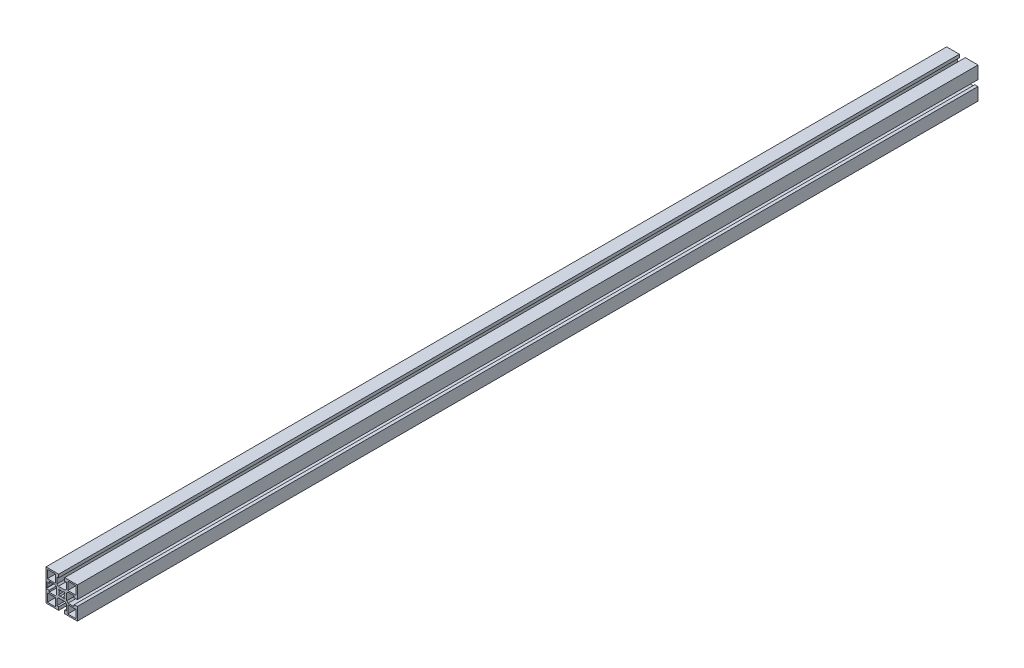
from build123d import *

# Parameters (mm, degrees)
SKETCH1_W           = 11.699975178
SKETCH1_H           = 11.699996949
SKETCH1_W_2         = 11.699990436
SKETCH1_H_2         = 11.699981689
SKETCH1_W_3         = 11.699990437
SKETCH1_H_3         = 11.699975177
SKETCH1_W_4         = 11.699981689
SKETCH1_H_4         = 11.699990436
BOSS_EXTRUDE1_DEPTH = 1292.86
CUT_EXTRUDE1_REACH  = 1295.252


with BuildPart() as part:
    # Sketch1 → Boss-Extrude1 (new body)
    with BuildSketch(Plane.XY):
        Polygon((22.500515052, 22.499297556), (-22.499484399, 22.499298105), (-22.499484948, -22.500701346), (-4.249491942, -22.500701568), (-4.249491942, -22.200733242), (-4.24949208, -18.000719999), (-6.799479919, -18.000719999), (-6.799480207, -9.200732353), (-4.799480391, -7.200732362), (4.800525817, -7.200732047), (6.8005258, -9.200731855), (6.800526088, -18.000720263), (4.250507877, -18.000720263), (4.250508015, -22.200733153), (4.250508015, -22.500701672), (22.500514502, -22.500701895), (22.500514725, -4.250714302), (22.200520351, -4.250714302), (18.000507108, -4.25071444), (18.000507108, -6.800702279), (9.200519462, -6.800702567), (7.200519471, -4.800702751), (7.200519156, 4.799303458), (9.200518964, 6.79930344), (18.000507424, 6.799303729), (18.000507424, 4.249285514), (22.200520261, 4.249285652), (22.500514829, 4.249285652), align=None)
        with BuildLine():
            Line((-4.249491247, 17.999291576), (-4.249490956, 22.199304807))
            Line((-4.249490956, 22.199304807), (-3.949472548, 22.199304807))
            Line((-3.949472548, 22.199304807), (-3.481695222, 21.73152644))
            ThreePointArc((-3.481695222, 21.73152644), (-2.670636178, 21.189593132), (-1.713926324, 20.999291428))
            Line((-1.713926324, 20.999291428), (1.714975167, 20.999291428))
            ThreePointArc((1.714975167, 20.999291428), (2.671722509, 21.189608628), (3.482801459, 21.731583767))
            Line((3.482801459, 21.731583767), (3.950490798, 22.199304487))
            Line((3.950490798, 22.199304487), (4.250509108, 22.199304487))
            Line((4.250509108, 22.199304487), (4.250508817, 17.999291575))
            Line((4.250508817, 17.999291575), (6.800527063, 17.999291575))
            Line((6.800527063, 17.999291575), (6.800526453, 9.199302988))
            Line((6.800526453, 9.199302988), (4.800526064, 7.199302969))
            Line((4.800526064, 7.199302969), (-4.799479817, 7.199303635))
            Line((-4.799479817, 7.199303635), (-6.799479854, 9.199304042))
            Line((-6.799479854, 9.199304042), (-6.799479244, 17.999291576))
            Line((-6.799479244, 17.999291576), (-4.249491247, 17.999291576))
        make_face(mode=Mode.SUBTRACT)
        with BuildLine():
            Line((-17.99949762, -4.250714253), (-22.199510799, -4.250714391))
            Line((-22.199510799, -4.250714391), (-22.199510799, -3.950696126))
            Line((-22.199510799, -3.950696126), (-21.731790056, -3.48300681))
            ThreePointArc((-21.731790056, -3.48300681), (-21.189814855, -2.671927844), (-20.999497617, -1.71518046))
            Line((-20.999497617, -1.71518046), (-20.999497617, 1.713721031))
            ThreePointArc((-20.999497617, 1.713721031), (-21.189799286, 2.670430863), (-21.731732544, 3.481489907))
            Line((-21.731732544, 3.481489907), (-22.199510888, 3.949267256))
            Line((-22.199510888, 3.949267256), (-22.199510888, 4.249285566))
            Line((-22.199510888, 4.249285566), (-17.999497356, 4.249285704))
            Line((-17.999497356, 4.249285704), (-17.999497356, 6.79927354))
            Line((-17.999497356, 6.79927354), (-9.199509947, 6.799273828))
            Line((-9.199509947, 6.799273828), (-7.199509956, 4.799274012))
            Line((-7.199509956, 4.799274012), (-7.199509641, -4.800732197))
            Line((-7.199509641, -4.800732197), (-9.199509449, -6.800732179))
            Line((-9.199509449, -6.800732179), (-17.99949762, -6.800732468))
            Line((-17.99949762, -6.800732468), (-17.99949762, -4.250714253))
        make_face(mode=Mode.SUBTRACT)
        with Locations((-14.649542346, -14.650709384)):
            Rectangle(SKETCH1_W, SKETCH1_H, mode=Mode.SUBTRACT)
        with Locations((14.65050626, -14.650767962)):
            Rectangle(SKETCH1_W_2, SKETCH1_H_2, mode=Mode.SUBTRACT)
        with BuildLine():
            Line((-3.181457266, -4.596908447), (-4.595670829, -3.182694885))
            Line((-4.595670829, -3.182694885), (-3.26221457, -1.849238626))
            ThreePointArc((-3.26221457, -1.849238626), (-3.749476751, -0.00071437), (-3.26221457, 1.847809887))
            Line((-3.26221457, 1.847809887), (-4.595670829, 3.181266146))
            Line((-4.595670829, 3.181266146), (-3.181457266, 4.595479708))
            Line((-3.181457266, 4.595479708), (-1.848001007, 3.262023449))
            ThreePointArc((-1.848001007, 3.262023449), (0.000523249, 3.74928563), (1.849047505, 3.262023449))
            Line((1.849047505, 3.262023449), (3.182503764, 4.595479708))
            Line((3.182503764, 4.595479708), (4.596717327, 3.181266146))
            Line((4.596717327, 3.181266146), (3.263261068, 1.847809887))
            ThreePointArc((3.263261068, 1.847809887), (3.750523249, -0.00071437), (3.263261068, -1.849238626))
            Line((3.263261068, -1.849238626), (4.596717327, -3.182694885))
            Line((4.596717327, -3.182694885), (3.182503764, -4.596908447))
            Line((3.182503764, -4.596908447), (1.849047505, -3.263452188))
            ThreePointArc((1.849047505, -3.263452188), (0.000523249, -3.75071437), (-1.848001007, -3.263452188))
            Line((-1.848001007, -3.263452188), (-3.181457266, -4.596908447))
        make_face(mode=Mode.SUBTRACT)
        with Locations((-14.64949028, 14.649335967)):
            Rectangle(SKETCH1_W_3, SKETCH1_H_3, mode=Mode.SUBTRACT)
        with Locations((14.650561583, 14.6492839)):
            Rectangle(SKETCH1_W_4, SKETCH1_H_4, mode=Mode.SUBTRACT)
    extrude(amount=BOSS_EXTRUDE1_DEPTH)

    # Sketch1_4 → Cut-Extrude1 (cut, up to next)
    with BuildSketch(Plane.XY, mode=Mode.PRIVATE) as cut_extrude1_sk1:
        with BuildLine():
            Line((-4.249490956, 22.499297883), (-4.249490956, 22.199304807))
            Line((-4.249490956, 22.199304807), (-3.949472548, 22.199304807))
            Line((-3.949472548, 22.199304807), (-3.481695222, 21.73152644))
            ThreePointArc((-3.481695222, 21.73152644), (-2.670636178, 21.189593132), (-1.713926324, 20.999291428))
            Line((-1.713926324, 20.999291428), (1.714975167, 20.999291428))
            ThreePointArc((1.714975167, 20.999291428), (2.671722509, 21.189608628), (3.482801459, 21.731583767))
            Line((3.482801459, 21.731583767), (3.950490798, 22.199304487))
            Line((3.950490798, 22.199304487), (4.250509108, 22.199304487))
            Line((4.250509108, 22.199304487), (4.250509108, 22.499297779))
            Line((4.250509108, 22.499297779), (-4.249490956, 22.499297883))
        make_face()
    cut_extrude1_tool1 = extrude(cut_extrude1_sk1.sketch, amount=CUT_EXTRUDE1_REACH, mode=Mode.PRIVATE) & part.part
    add(cut_extrude1_tool1.solids().sort_by_distance((0.000518, 21.824215, 0))[0], mode=Mode.SUBTRACT)


solid = part.part
